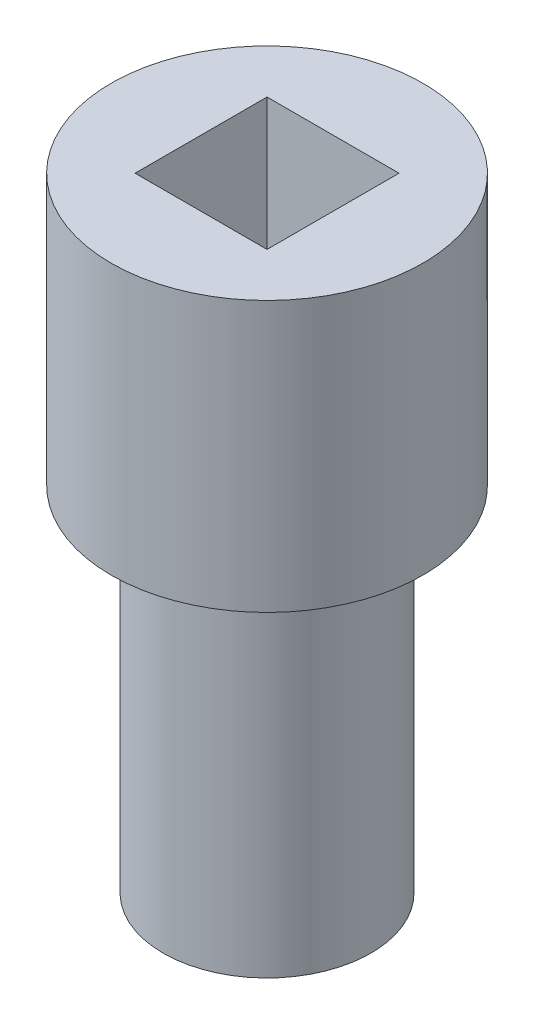
from build123d import *

# Parameters (mm, degrees)
SKETCH2_R           = 7.5
SKETCH2_R_2         = 5
SKETCH2_W           = 6.35
SKETCH2_H           = 6.35
BOSS_EXTRUDE1_DEPTH = 10
SKETCH2_4_R         = 5
BOSS_EXTRUDE2_DEPTH = 20
SKETCH2_5_R         = 7.5
SKETCH2_5_R_2       = 5
BOSS_EXTRUDE3_DEPTH = 3
SKETCH3_R           = 2
CUT_EXTRUDE1_DEPTH  = 8.5


with BuildPart() as part:
    # Sketch2 → Boss-Extrude1 (new body)
    with BuildSketch(Plane(origin=(0, 0, 0), x_dir=(1, 0, 0), z_dir=(0, 1, 0))):
        with Locations(Location((0, 0, 0), (0, 0, 270))):
            Circle(SKETCH2_R)
        Circle(SKETCH2_R_2, mode=Mode.SUBTRACT)
        Circle(SKETCH2_R_2)
        Rectangle(SKETCH2_W, SKETCH2_H, mode=Mode.SUBTRACT)
    extrude(amount=BOSS_EXTRUDE1_DEPTH)

    # Sketch2_4 → Boss-Extrude2 (add)
    with BuildSketch(Plane(origin=(0, 0, 0), x_dir=(1, 0, 0), z_dir=(0, 1, 0))):
        with Locations(Location((0, 0, 0), (0, 0, 270))):
            Circle(SKETCH2_4_R)
    extrude(amount=-BOSS_EXTRUDE2_DEPTH)

    # Sketch2_5 → Boss-Extrude3 (add)
    with BuildSketch(Plane(origin=(0, 0, 0), x_dir=(1, 0, 0), z_dir=(0, 1, 0))):
        with Locations(Location((0, 0, 0), (0, 0, 270))):
            Circle(SKETCH2_5_R)
        with Locations(Location((0, 0, 0), (0, 0, 270))):
            Circle(SKETCH2_5_R_2, mode=Mode.SUBTRACT)
    extrude(amount=-BOSS_EXTRUDE3_DEPTH)

    # Sketch3 → Cut-Extrude1 (cut)
    with BuildSketch(Plane.XZ.offset(20)):
        with Locations(Location((0, 0, 0), (0, 0, 270))):
            Circle(SKETCH3_R)
    extrude(amount=-CUT_EXTRUDE1_DEPTH, mode=Mode.SUBTRACT)


solid = part.part
